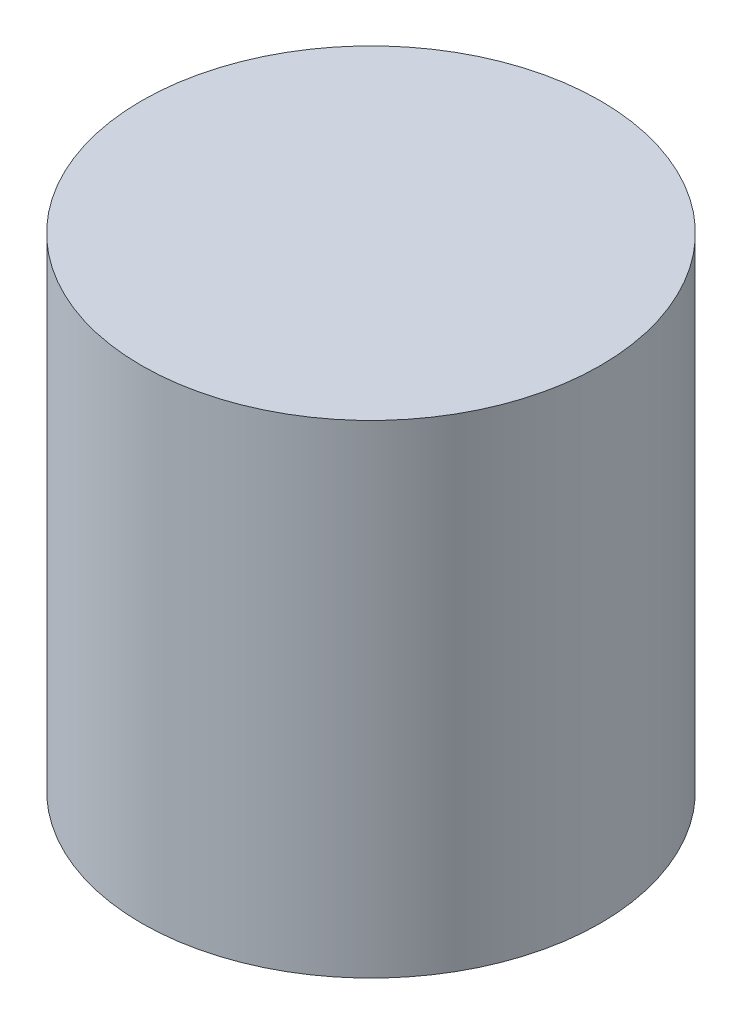
from build123d import *

# Parameters (mm, degrees)
SKETCH1_R           = 24.13
BOSS_EXTRUDE2_DEPTH = 50.8


with BuildPart() as part:
    # Sketch1 → Boss-Extrude2 (new body)
    with BuildSketch(Plane(origin=(0, 0, 0), x_dir=(1, 0, 0), z_dir=(0, 1, 0))):
        with Locations((-78.989108214, -92.526110859)):
            Circle(SKETCH1_R)
    extrude(amount=BOSS_EXTRUDE2_DEPTH)


solid = part.part
